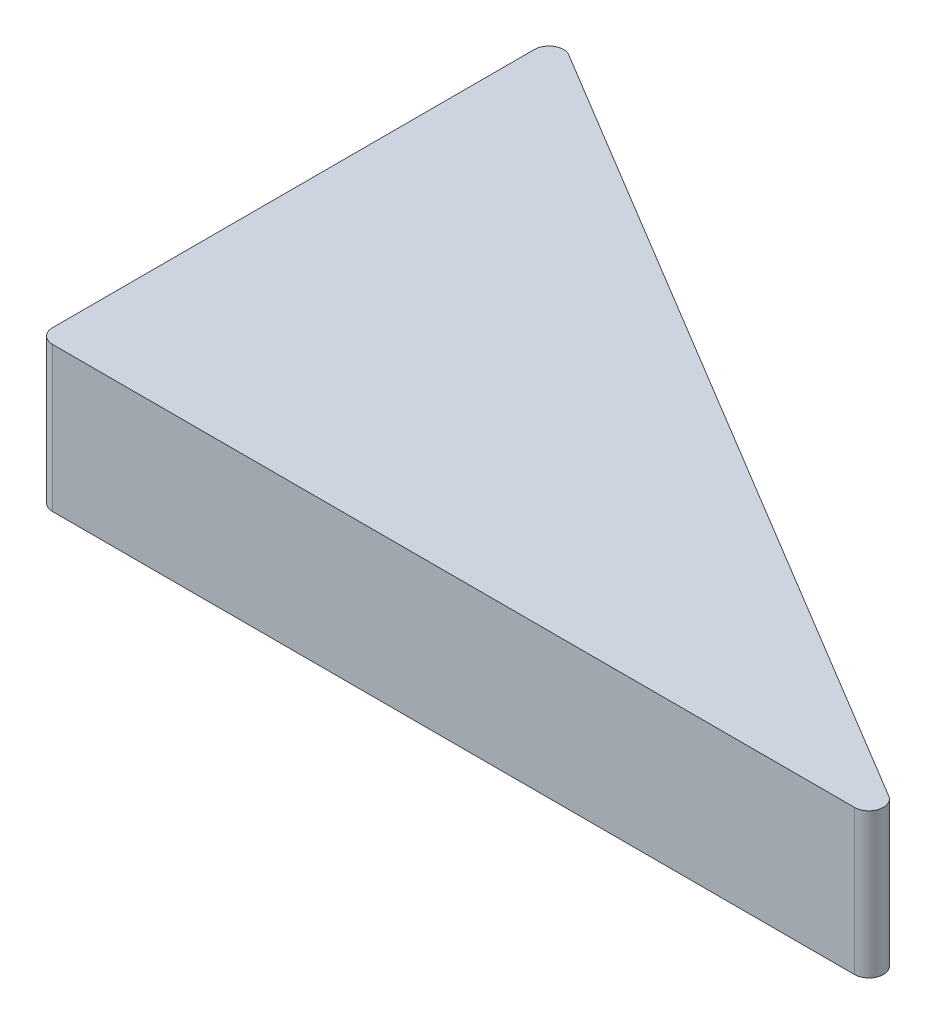
from build123d import *

# Parameters (mm, degrees)
BOSS_EXTRUDE1_DEPTH = 10


with BuildPart() as part:
    # Sketch1 → Boss-Extrude1 (new body)
    with BuildSketch(Plane(origin=(0, 0, 0), x_dir=(1, 0, 0), z_dir=(0, 1, 0))):
        with BuildLine():
            Line((0, 1), (0, 34.287920875))
            ThreePointArc((0, 34.287920875), (0.507597093, 35.158288256), (1.515078754, 35.145063733))
            Line((1.515078754, 35.145063733), (56.909527478, 1.857142857))
            ThreePointArc((56.909527478, 1.857142857), (57.358072836, 0.732738758), (56.394448725, 0))
            Line((56.394448725, 0), (1, 0))
            ThreePointArc((1, 0), (0.292893219, 0.292893219), (0, 1))
        make_face()
    extrude(amount=BOSS_EXTRUDE1_DEPTH)


solid = part.part
